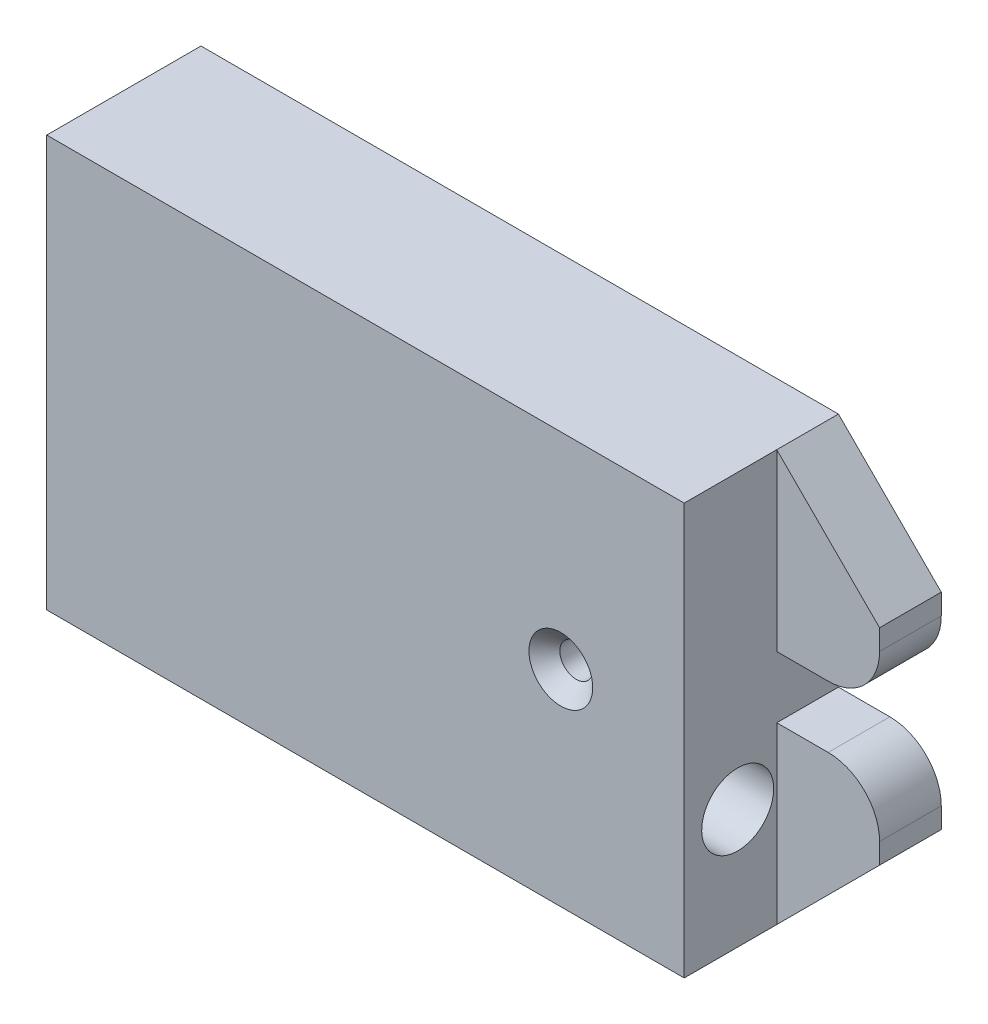
from build123d import *

# Parameters (mm, degrees)
ESQUISSE1_W               = 62
ESQUISSE1_H               = 40
ESQUISSE1_R               = 1.6
EXTRUSION1_DEPTH          = 15
EXTRUSION2_DEPTH          = 6
CONG_1_R                  = 5
CHANFREIN1_SIZE           = 1.5
ESQUISSE3_R               = 3.1
ENL_V_MAT_EXTRU_1_DEPTH   = 73
ESQUISSE4_R               = 3.5
ENL_V_MAT_EXTRU_2_DEPTH   = 10
TROU_TARAUD_M5X0_81_D     = 4.2
TROU_TARAUD_M5X0_81_DEPTH = 22
TROU_TARAUD_M5X0_81_TIP   = 1.2618073


with BuildPart() as part:
    # Esquisse1 → Extrusion1 (new body)
    with BuildSketch(Plane.XY):
        Rectangle(ESQUISSE1_W, ESQUISSE1_H)
        with Locations((19, 0)):
            Circle(ESQUISSE1_R, mode=Mode.SUBTRACT)
    extrude(amount=EXTRUSION1_DEPTH)

    # Esquisse2 → Extrusion2 (add)
    with BuildSketch(Plane(origin=(0, 0, 0), x_dir=(-1, 0, 0), z_dir=(0, 0, -1))):
        Polygon((-31, 3), (-31, 20), (-41, 10), (-41, 3), align=None)
        Polygon((-31, -20), (-31, -3), (-41, -3), (-41, -10), align=None)
    extrude(amount=-EXTRUSION2_DEPTH)

    # Congé1
    cong_1_edges = [part.edges().sort_by_distance(p)[0] for p in [
        (41, -3, 3),
        (41, 3, 3),
    ]]
    fillet(cong_1_edges, radius=CONG_1_R)

    # Chanfrein1
    chanfrein1_edges = [part.edges().sort_by_distance(p)[0] for p in [
        (17.4, 0, 15),
    ]]
    chamfer(chanfrein1_edges, length=CHANFREIN1_SIZE)

    # Esquisse3 → Enlèv. mat.-Extru.1 (cut, through all)
    with BuildSketch(Plane.ZY.offset(31)):
        with Locations(Location((9.8, -8.8, 0), (0, 0, 270))):  # turned: the seam where the file's is
            Circle(ESQUISSE3_R)
    extrude(amount=-ENL_V_MAT_EXTRU_1_DEPTH, mode=Mode.SUBTRACT)

    # Esquisse4 → Enlèv. mat.-Extru.2 (cut)
    with BuildSketch(Plane(origin=(31, 0, 0), x_dir=(0, 0, -1), z_dir=(1, 0, 0))):
        with Locations(Location((-9.8, -8.4, 0), (0, 0, 90))):  # turned: the seam where the file's is
            Circle(ESQUISSE4_R)
    extrude(amount=-ENL_V_MAT_EXTRU_2_DEPTH, mode=Mode.SUBTRACT)

    # Trou taraudé M5x0.81
    with Locations(Plane(origin=(-31, 6.2, 7.5), x_dir=(0, -1, 0), z_dir=(-1, 0, 0))):
        with Locations((0, 0)):
            Hole(TROU_TARAUD_M5X0_81_D / 2, depth=TROU_TARAUD_M5X0_81_DEPTH)
            with Locations((0, 0, -(TROU_TARAUD_M5X0_81_DEPTH + TROU_TARAUD_M5X0_81_TIP / 2))):  # 118° drill point
                Cone(0, TROU_TARAUD_M5X0_81_D / 2, TROU_TARAUD_M5X0_81_TIP, mode=Mode.SUBTRACT)


solid = part.part
